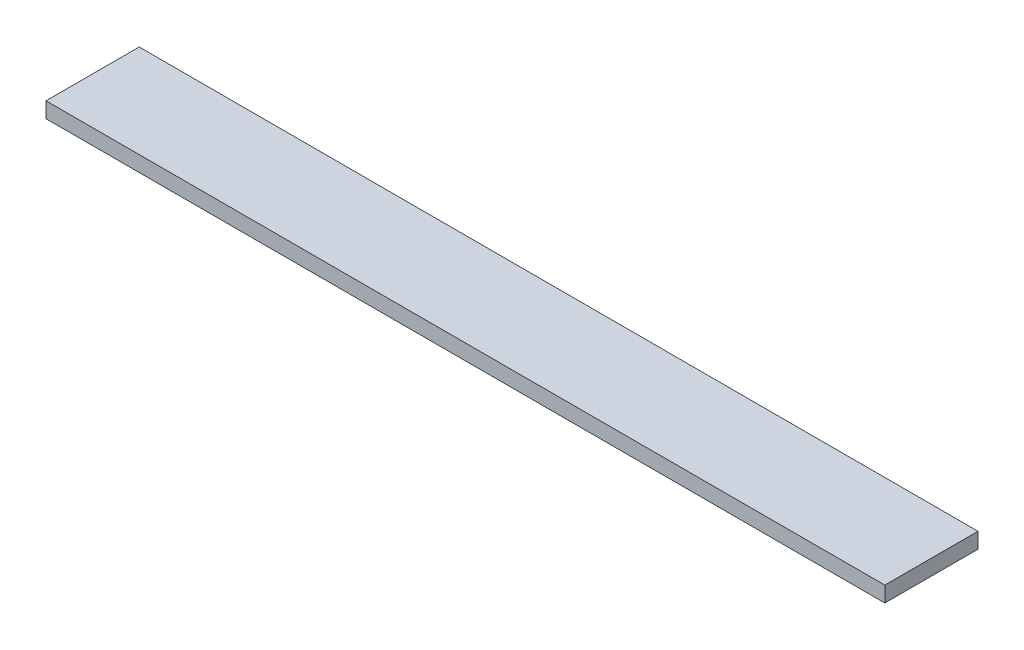
from build123d import *

# Parameters (mm, degrees)
SKETCH1_W           = 685.8
SKETCH1_H           = 76.2
BOSS_EXTRUDE1_DEPTH = 12.7


with BuildPart() as part:
    # Sketch1 → Boss-Extrude1 (new body)
    with BuildSketch(Plane(origin=(0, 0, 0), x_dir=(1, 0, 0), z_dir=(0, 1, 0))):
        with Locations((-342.9, -38.1)):
            Rectangle(SKETCH1_W, SKETCH1_H)
    extrude(amount=BOSS_EXTRUDE1_DEPTH)


solid = part.part
